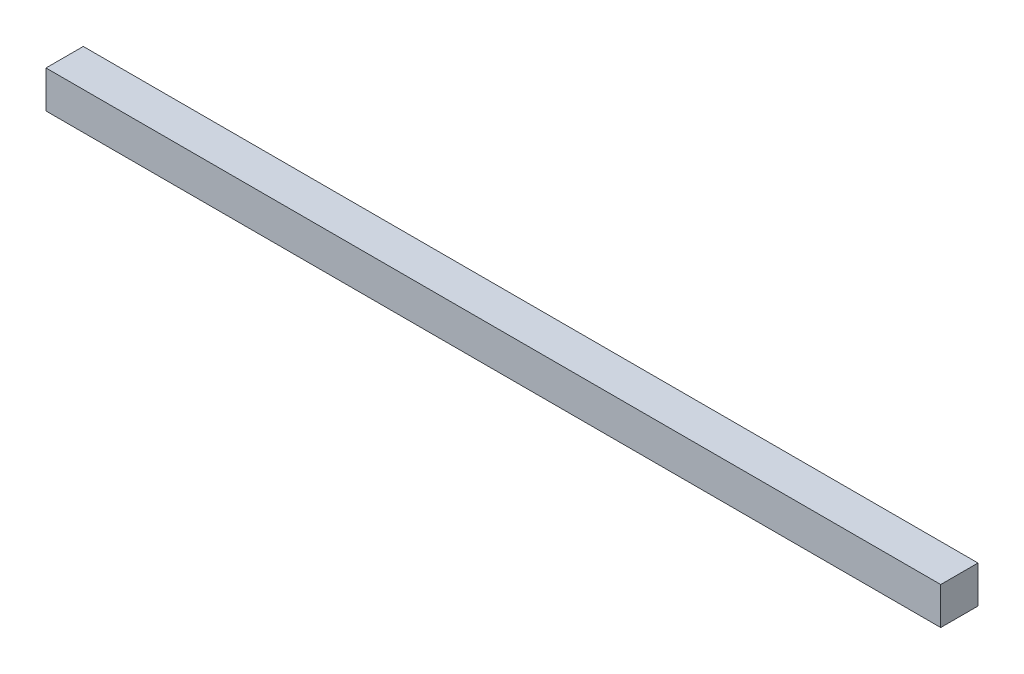
from build123d import *

# Parameters (mm, degrees)
SKETCH1_W           = 609.6
SKETCH1_H           = 25.4
BOSS_EXTRUDE1_DEPTH = 25.4


with BuildPart() as part:
    # Sketch1 → Boss-Extrude1 (new body)
    with BuildSketch(Plane(origin=(0, 0, 0), x_dir=(1, 0, 0), z_dir=(0, 1, 0))):
        with Locations((257.851007269, 8.284777054)):
            Rectangle(SKETCH1_W, SKETCH1_H)
    extrude(amount=BOSS_EXTRUDE1_DEPTH)


solid = part.part
